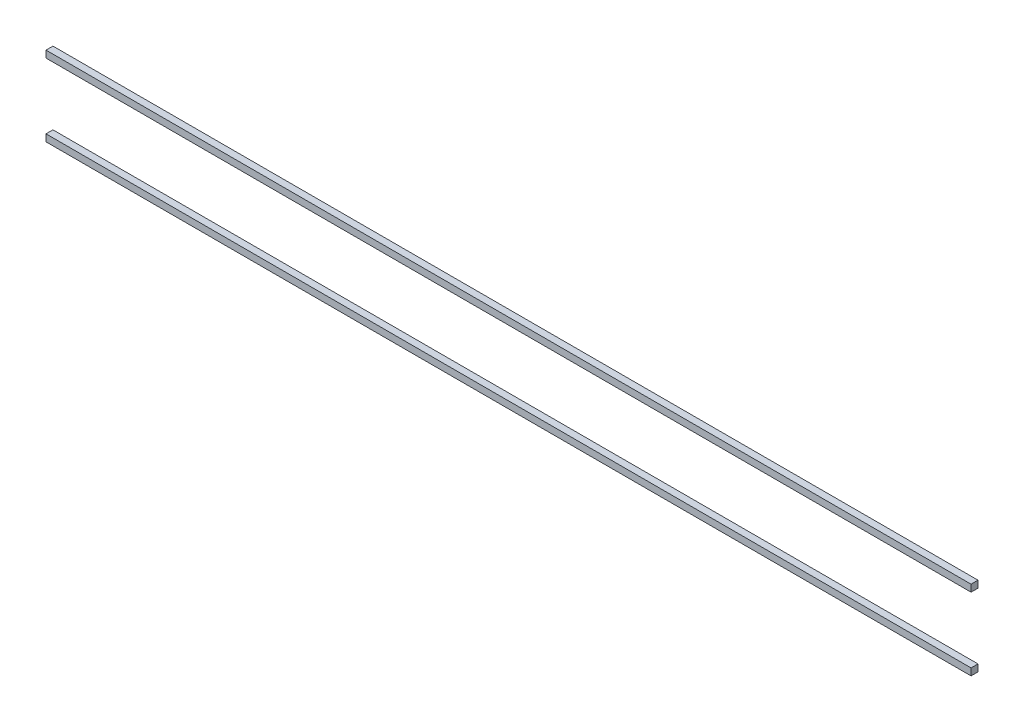
from build123d import *

# Parameters (mm, degrees)
BOSS_EXTRUDE1_DEPTH   = 3.175
BOSS_EXTRUDE1_2_DEPTH = 3.175


with BuildPart() as part:
    # Sketch1 → Boss-Extrude1 (new body)
    with BuildSketch(Plane.XY):
        Polygon((15, 45), (405, 45), (405, 48.175), (18.175, 48.175), (-18.175, 48.175), (-18.175, 45), (-15, 45), align=None)
    extrude(amount=BOSS_EXTRUDE1_DEPTH)


with BuildPart() as body_2:
    # Sketch1 → Boss-Extrude1 2 (new body)
    with BuildSketch(Plane.XY):
        Polygon((-18.175, 15), (-15, 15), (15, 15), (405, 15), (405, 11.825), (18.175, 11.825), (-18.175, 11.825), align=None)
    extrude(amount=BOSS_EXTRUDE1_2_DEPTH)


solid = Compound([part.part, body_2.part])
